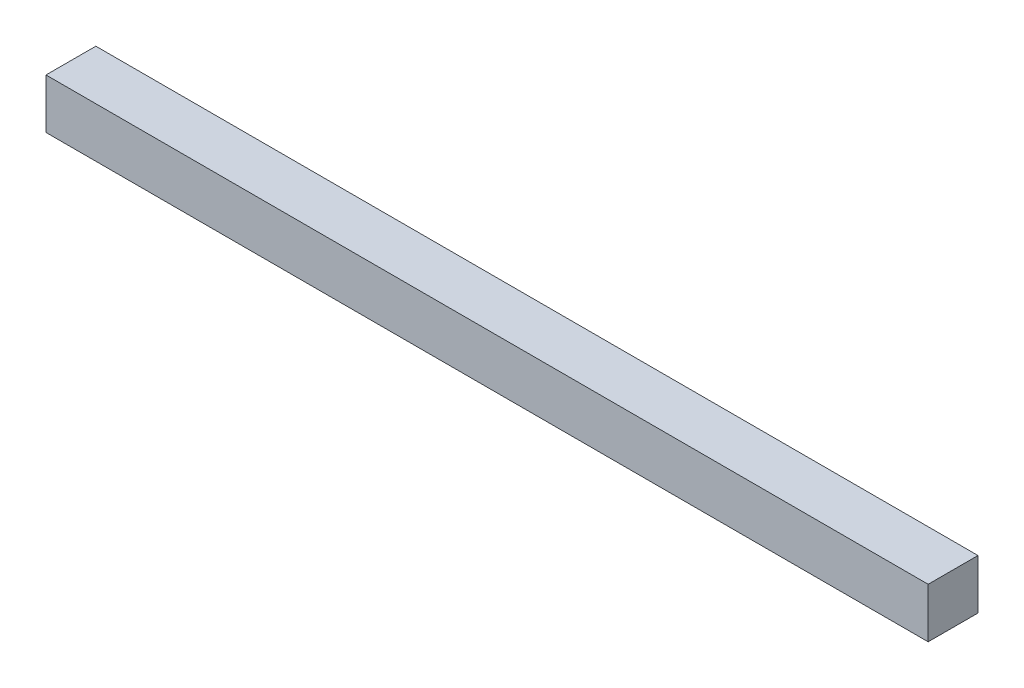
from build123d import *

# Parameters (mm, degrees)
ESQUISSE1_W        = 177
ESQUISSE1_H        = 10
BOSS_EXTRU_1_DEPTH = 10


with BuildPart() as part:
    # Esquisse1 → Boss.-Extru.1 (new body)
    with BuildSketch(Plane.XY):
        with Locations((-27.723225214, 34.186046512)):
            Rectangle(ESQUISSE1_W, ESQUISSE1_H)
    extrude(amount=BOSS_EXTRU_1_DEPTH)


solid = part.part
